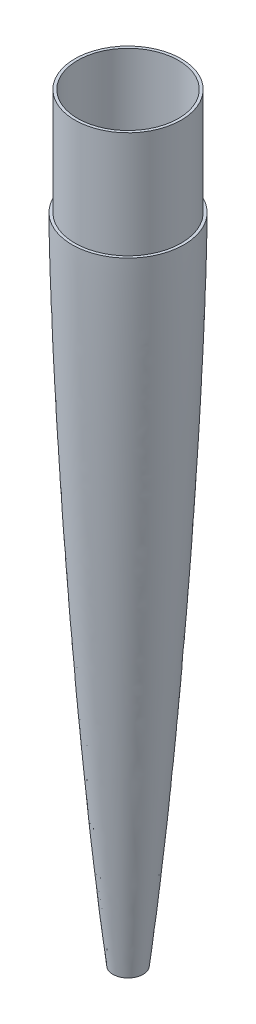
from build123d import *


with BuildPart() as part:
    # Sketch1 → Revolve2 (revolve)
    with BuildSketch(Plane.XY):
        with BuildLine():
            Line((-60, 0), (-57.030000005, 0))
            Line((-57.030000005, 0), (-57.030000005, 114.300000001))
            Line((-57.030000005, 114.300000001), (-54.060000005, 114.300000001))
            Line((-54.060000005, 114.300000001), (-54.060000005, 1e-09))
            Line((-54.060000005, 1e-09), (-54.976899678, -95.267420724))
            add(Edge.make_bspline(
                [(-54.976899678, -95.267420724), (-54.910918352, -97.329553616), (-54.334867215, -115.057444063), (-53.077955961, -149.281209118), (-50.275970448, -214.422054541), (-46.024079242, -296.858704346), (-40.929694817, -379.246418027), (-36.336675621, -445.121102939), (-32.617977146, -494.507030379), (-28.601307552, -543.867289656), (-24.246866319, -593.195799191), (-19.628286478, -641.041699054), (-16.063745057, -674.473253853), (-13.992765453, -692.562507303), (-13.629103424, -695.696740322), (-13.502527845, -696.782430891)],
                knots=[0.118780058, 0.118780058, 0.118780058, 0.118780058, 0.126491537, 0.185075474, 0.246767298, 0.370150947, 0.493534596, 0.555226421, 0.616918245, 0.67861007, 0.740301894, 0.801993719, 0.858276893, 0.865988371, 0.87007583, 0.87007583, 0.87007583, 0.87007583], degree=3))
            Line((-13.502527845, -696.782430891), (-13.164438765, -699.67))
            Line((-13.164438765, -699.67), (-16.1548803, -699.67))
            add(Edge.make_bspline(
                [(-60, 0), (-60, -0.801301824), (-59.992858014, -2.134935758), (-59.98048707, -4.395895866), (-59.96251556, -6.544624516), (-59.942761818, -8.749908515), (-59.919055681, -10.925483502), (-59.894059366, -13.116761755), (-59.866178739, -15.299547638), (-59.836621266, -17.48683519), (-59.80514679, -19.671667321), (-59.771541464, -21.858055356), (-59.736867908, -24.043503346), (-59.700043709, -26.229650559), (-59.66204493, -28.41526885), (-59.622459621, -30.601327879), (-59.581547217, -32.787003018), (-59.538995019, -34.972696398), (-59.495607768, -37.158385038), (-59.450302943, -39.34406904), (-59.404469233, -41.530099826), (-59.356787893, -43.715780933), (-59.308588024, -45.901808333), (-59.258630434, -48.087490166), (-59.208100543, -50.273187043), (-59.155819313, -52.458864623), (-59.103495156, -54.644569067), (-59.048276425, -56.830561965), (-58.994274985, -59.016276927), (-58.938221442, -61.202296633), (-58.881140769, -63.387981946), (-58.823355444, -65.574008856), (-58.764379524, -67.759688478), (-58.704665809, -69.945374772), (-58.643925455, -72.131063874), (-58.582319142, -74.316753088), (-58.519674699, -76.502771688), (-58.456509605, -78.688463984), (-58.392124534, -80.874483057), (-58.327106119, -83.060179384), (-58.261198983, -85.245982329), (-58.194209713, -87.431660434), (-58.127297802, -89.61736007), (-58.058647275, -91.803260902), (-57.989251169, -93.988944863), (-57.919504151, -96.174974634), (-57.848643133, -98.360657974), (-57.777245448, -100.546676496), (-57.705052501, -102.732368286), (-57.607762905, -105.646864011), (-57.508846666, -108.561004505), (-57.408627348, -111.475463532), (-57.332851064, -113.661158289), (-57.256046683, -115.847173485), (-57.179035511, -118.032871552), (-57.100710846, -120.218547193), (-57.022009698, -122.40423276), (-56.942857414, -124.589926107), (-56.862296371, -126.775926431), (-56.782243077, -128.96164674), (-56.699699006, -131.147635149), (-56.618336348, -133.333360228), (-56.535453881, -135.519371841), (-56.452132799, -137.705058585), (-56.367953748, -139.890737929), (-56.283265361, -142.076429794), (-56.19801461, -144.262121161), (-56.111932015, -146.448137697), (-56.025500016, -148.633833532), (-55.937916927, -150.819842926), (-55.850276009, -153.005543945), (-55.76134219, -155.191213723), (-55.643051191, -158.105392465), (-55.522717339, -161.019854888), (-55.401601937, -163.934321952), (-55.309872078, -166.120335129), (-55.218077571, -168.306038315), (-55.124824644, -170.492033851), (-55.032082371, -172.677748721), (-54.937643699, -174.863408092), (-54.843635874, -177.049121618), (-54.748038186, -179.234791682), (-54.652569374, -181.420836883), (-54.556479629, -183.606533338), (-54.459475917, -185.792547103), (-54.362188819, -187.978234727), (-54.264269964, -190.163924556), (-54.165587671, -192.349599766), (-54.066616508, -194.535290959), (-53.966784556, -196.721302604), (-53.866693946, -198.906999552), (-53.765933644, -201.093026138), (-53.664741488, -203.278718394), (-53.562574071, -205.464729689), (-53.46015287, -207.650414823), (-53.357451076, -209.836114668), (-53.25379016, -212.021793327), (-53.149897537, -214.207484038), (-53.045189805, -216.393500975), (-52.939966643, -218.579191869), (-52.834346122, -220.765225661), (-52.72802674, -222.95090942), (-52.621553388, -225.136604178), (-52.513848545, -227.32227415), (-52.40670358, -229.508001007), (-52.297171846, -231.693961127), (-52.189930068, -233.879735673), (-52.079082133, -236.065676373), (-51.969910846, -238.251412967), (-51.85901638, -240.437401634), (-51.748265493, -242.623099873), (-51.636731103, -244.808784209), (-51.524563121, -246.994461643), (-51.41233969, -249.180169949), (-51.298859714, -251.366169958), (-51.185781728, -253.551885484), (-51.071121402, -255.737881493), (-50.956939094, -257.923591641), (-50.841400016, -260.109265018), (-50.726212458, -262.29498087), (-50.609806822, -264.480661757), (-50.493089081, -266.666677341), (-50.376072117, -268.852372888), (-50.2582093, -271.038380358), (-50.140185668, -273.224081487), (-50.021331093, -275.409964495), (-49.902264979, -277.595663351), (-49.782525037, -279.781345211), (-49.662222809, -281.96715596), (-49.541568082, -284.152841674), (-49.420204402, -286.338856279), (-49.298798343, -288.524573428), (-49.175813178, -290.710555166), (-49.054627889, -292.896341283), (-48.929555276, -295.081919321), (-48.80703709, -297.267689436), (-48.682200389, -299.453344602), (-48.557622575, -301.63937574), (-48.432377268, -303.825065531), (-48.306604756, -306.011076632), (-48.138301508, -308.925568974), (-47.968757752, -311.840024396), (-47.798650693, -314.754161782), (-47.670344167, -316.939847051), (-47.541698169, -319.125548351), (-47.41222605, -321.311556797), (-47.282518137, -323.497255833), (-47.152537397, -325.68329376), (-47.021571672, -327.868970857), (-46.890540884, -330.05467291), (-46.758438058, -332.240330723), (-46.626631093, -334.426034491), (-46.493724324, -336.612038639), (-46.360537695, -338.797731393), (-46.226723482, -340.983758972), (-46.092732037, -343.169463313), (-45.957681737, -345.355362203), (-45.822817455, -347.541074097), (-45.686540199, -349.726720561), (-45.551343277, -351.912568316), (-45.413978364, -354.098210705), (-45.27660323, -356.284223198), (-45.139053758, -358.469936355), (-45.000763617, -360.655955619), (-44.86203954, -362.841656073), (-44.722923977, -365.027353453), (-44.582999362, -367.21302593), (-44.44309759, -369.398736621), (-44.301914301, -371.584719331), (-44.160935543, -373.770425312), (-44.019209139, -375.956439275), (-43.876769511, -378.142115164), (-43.734218837, -380.327899792), (-43.590938835, -382.513586347), (-43.447088586, -384.69926936), (-43.302846381, -386.885214629), (-43.158036869, -389.07090708), (-43.012913506, -391.256947279), (-42.866890616, -393.442611195), (-42.720711356, -395.628637304), (-42.57379855, -397.814315117), (-42.426490997, -400.000021171), (-42.278628488, -402.185713002), (-42.130254761, -404.371392804), (-41.981568615, -406.557429677), (-41.831681394, -408.743075027), (-41.682828376, -410.92916822), (-41.531510493, -413.114784676), (-41.330439397, -416.029298352), (-41.128056224, -418.943436932), (-40.924663592, -421.857882421), (-40.771744547, -424.043579315), (-40.618076428, -426.22959461), (-40.464009098, -428.415295234), (-40.309205215, -430.601315556), (-40.154312127, -432.787028349), (-39.99863944, -434.972710046), (-39.842152913, -437.158365607), (-39.685814825, -439.344094129), (-39.52808724, -441.530081544), (-39.370694913, -443.715806359), (-39.211862327, -445.901785529), (-39.053403335, -448.087522124), (-38.893639517, -450.273297547), (-38.733738096, -452.458987048), (-38.573226107, -454.644664914), (-38.41208941, -456.830568481), (-38.250643552, -459.016289263), (-38.088118005, -461.202280635), (-37.925733991, -463.388006805), (-37.762033172, -465.573994828), (-37.597960177, -467.759671106), (-37.434333947, -469.945406433), (-37.268766086, -472.131043433), (-37.103624375, -474.316764751), (-36.937277162, -476.502778388), (-36.770677476, -478.688464011), (-36.603339409, -480.874477936), (-36.435566057, -483.06017656), (-36.267208759, -485.245881682), (-36.098010633, -487.431559843), (-35.928747445, -489.617272102), (-35.758303916, -491.803273105), (-35.587725669, -493.988973654), (-35.416406694, -496.17499239), (-35.24443382, -498.360674999), (-35.072049118, -500.546710875), (-34.898922146, -502.732404615), (-34.667151047, -505.646902354), (-34.43456829, -508.561067682), (-34.200313769, -511.475477223), (-34.024304915, -513.661157965), (-33.847353496, -515.847147357), (-33.670779824, -518.032918232), (-33.491732112, -520.21866423), (-33.313572689, -522.404386438), (-33.134237451, -524.590066145), (-32.95415861, -526.775947698), (-32.774006064, -528.961669566), (-32.59240474, -531.147650911), (-32.410922159, -533.333354764), (-32.228195825, -535.51936234), (-32.045138628, -537.705064649), (-31.861206714, -539.890749257), (-31.67668942, -542.076440099), (-31.491950547, -544.262152097), (-31.305924361, -546.448161538), (-31.119329898, -548.633846995), (-30.932322619, -550.819875434), (-30.744507905, -553.005570214), (-30.555977806, -555.191260582), (-30.36652527, -557.376929049), (-30.177192953, -559.562665124), (-29.985666111, -561.748602994), (-29.794943847, -563.93436667), (-29.602713105, -566.120357514), (-29.409925869, -568.306050437), (-29.216509259, -570.492084484), (-29.02205264, -572.677756942), (-28.827321473, -574.863463769), (-28.631319546, -577.049111422), (-28.435242486, -579.234842067), (-28.237450587, -581.420811966), (-28.039775325, -583.606534105), (-27.840828887, -585.792549196), (-27.641363771, -587.978245938), (-27.441068518, -590.163943402), (-27.239817856, -592.349628243), (-27.0380143, -594.535347519), (-26.834843959, -596.721325459), (-26.631931269, -598.907071959), (-26.426637245, -601.092994458), (-26.222215448, -603.278758694), (-26.015644194, -605.4647156), (-25.808938096, -607.650420412), (-25.601048983, -609.836107743), (-25.392425956, -612.021819265), (-25.182943681, -614.207535647), (-24.972300709, -616.393547963), (-24.761180821, -618.579245775), (-24.54873058, -620.765243183), (-24.335610495, -622.950940724), (-24.121675392, -625.136655174), (-23.906299598, -627.322305823), (-23.690750483, -629.508036765), (-23.473088531, -631.693979902), (-23.256298117, -633.8797989), (-23.036339334, -636.065712517), (-22.816790067, -638.251465366), (-22.595568041, -640.437451396), (-22.37382784, -642.623161306), (-22.150636062, -644.808818844), (-21.926517879, -646.99450118), (-21.701733242, -649.180231976), (-21.474931493, -651.36619235), (-21.248017068, -653.551943093), (-21.019029725, -655.737918981), (-20.789829622, -657.923669499), (-20.481575316, -660.838186303), (-20.17186238, -663.752385107), (-19.859263751, -666.666750242), (-19.623758946, -668.852440953), (-19.386668524, -671.038438197), (-19.148621967, -673.224159459), (-18.908853729, -675.410154942), (-18.668383585, -677.595878389), (-18.4259741, -679.781542734), (-18.18254924, -681.967245551), (-17.937557318, -684.152919888), (-17.691134792, -686.338934942), (-17.360468135, -689.253500161), (-17.027092261, -692.168023287), (-16.690290755, -695.082034686), (-16.436360122, -697.267741079), (-16.257396502, -698.797019741), (-16.163352105, -699.59787912), (-16.1548803, -699.67)],
                knots=[0, 0, 0, 0, 0.002721315, 0.005443895, 0.008165279, 0.010887941, 0.013609388, 0.016332111, 0.019053617, 0.021775487, 0.024497974, 0.0272196, 0.029942492, 0.03266416, 0.035387117, 0.038108852, 0.04083186, 0.043553666, 0.046275496, 0.048998614, 0.051720527, 0.054443713, 0.057165667, 0.05988892, 0.062610956, 0.065333013, 0.068056339, 0.070778475, 0.073501855, 0.076224025, 0.078947511, 0.081669751, 0.084393271, 0.087115584, 0.089837927, 0.092561566, 0.095283969, 0.098007652, 0.100730126, 0.103453879, 0.106176423, 0.108899388, 0.11162279, 0.114345403, 0.117069304, 0.119792003, 0.122515947, 0.125238701, 0.127962718, 0.130685546, 0.136132527, 0.138855426, 0.141579611, 0.144302595, 0.147026824, 0.149749851, 0.15247292, 0.155197234, 0.157920346, 0.160644746, 0.163367944, 0.166092386, 0.168815634, 0.171540127, 0.174263426, 0.176986776, 0.179711393, 0.182434776, 0.185159464, 0.187882937, 0.190607665, 0.193331212, 0.196054764, 0.201503213, 0.204228129, 0.206951815, 0.209676745, 0.212400514, 0.215125513, 0.217849317, 0.220573138, 0.22329827, 0.226022159, 0.228747349, 0.231471296, 0.234196523, 0.23692055, 0.239644613, 0.24236992, 0.245094057, 0.247819466, 0.250543645, 0.253269127, 0.255993366, 0.258718906, 0.261443215, 0.264167557, 0.266893186, 0.269617579, 0.272343283, 0.275067784, 0.277793528, 0.280518047, 0.283242615, 0.285968485, 0.288693112, 0.291418982, 0.294143732, 0.296869661, 0.29959444, 0.302320472, 0.305045289, 0.307770171, 0.310496302, 0.313221247, 0.315947465, 0.318672457, 0.321398759, 0.324123818, 0.326848941, 0.329575331, 0.3323005, 0.335026935, 0.337752191, 0.340478691, 0.343204014, 0.345930114, 0.348655969, 0.351381361, 0.354108055, 0.35683351, 0.359560274, 0.362285861, 0.365012625, 0.367738286, 0.370463914, 0.373190851, 0.375916585, 0.378643563, 0.381369371, 0.384096423, 0.389549442, 0.392275386, 0.395001377, 0.397728625, 0.400454703, 0.403182024, 0.405908168, 0.408635572, 0.411361766, 0.414088017, 0.416815493, 0.419541792, 0.422269409, 0.424995782, 0.427723473, 0.43044992, 0.433177256, 0.435904206, 0.438630727, 0.441358565, 0.444085241, 0.44681316, 0.449539919, 0.452267919, 0.454994756, 0.457721599, 0.460449704, 0.463176679, 0.465904847, 0.468631871, 0.471360177, 0.474087261, 0.476814716, 0.479542836, 0.482270046, 0.484998573, 0.487725891, 0.490454473, 0.493181817, 0.495910524, 0.498637988, 0.501365534, 0.504094322, 0.506821867, 0.509550818, 0.512278446, 0.515007397, 0.517735195, 0.523192122, 0.525920017, 0.528649229, 0.531377241, 0.534106519, 0.536834668, 0.539564066, 0.542292224, 0.545020465, 0.547749983, 0.550478375, 0.553207951, 0.555936403, 0.558666126, 0.561394697, 0.564123645, 0.566853084, 0.569581775, 0.572311733, 0.575040571, 0.577770563, 0.580499491, 0.58322966, 0.585958588, 0.588687613, 0.591417977, 0.594147099, 0.59687756, 0.599606779, 0.602337336, 0.605066749, 0.607796162, 0.610526865, 0.613256424, 0.615987255, 0.61871688, 0.621447837, 0.624177605, 0.626908668, 0.629638566, 0.635099741, 0.637829799, 0.640561099, 0.643291255, 0.646022749, 0.648753107, 0.651483929, 0.654215066, 0.656945629, 0.659677437, 0.662408005, 0.665139987, 0.667870727, 0.670602815, 0.673333763, 0.676064713, 0.678797008, 0.681528102, 0.684260567, 0.686991831, 0.689724335, 0.692455808, 0.695187282, 0.697919996, 0.700651678, 0.703384602, 0.706116397, 0.708849432, 0.711581437, 0.714314712, 0.717046752, 0.719778976, 0.722512462, 0.725244836, 0.727978528, 0.73071105, 0.733444946, 0.736177626, 0.738910432, 0.741644603, 0.744377596, 0.747111829, 0.749845046, 0.752579504, 0.755312842, 0.758047546, 0.760781117, 0.763514816, 0.766249873, 0.768983774, 0.771718989, 0.774453048, 0.777188544, 0.779922883, 0.782657299, 0.785393079, 0.788127774, 0.79086375, 0.793598736, 0.79633496, 0.799070192, 0.801806681, 0.804542081, 0.807277673, 0.810014608, 0.812750444, 0.815487662, 0.818223866, 0.820961325, 0.823697799, 0.829172385, 0.831909259, 0.834647506, 0.837384785, 0.840123438, 0.842861051, 0.845600047, 0.848337974, 0.851076155, 0.853815708, 0.85655416, 0.859294194, 0.864773562, 0.867513015, 0.870252618, 0.872993689, 0.873264965, 0.873264965, 0.873264965, 0.873264965], degree=3))
        make_face()
    revolve(axis=Axis((0, -789.4471984, 0), (0, 1, 0)))


solid = part.part
